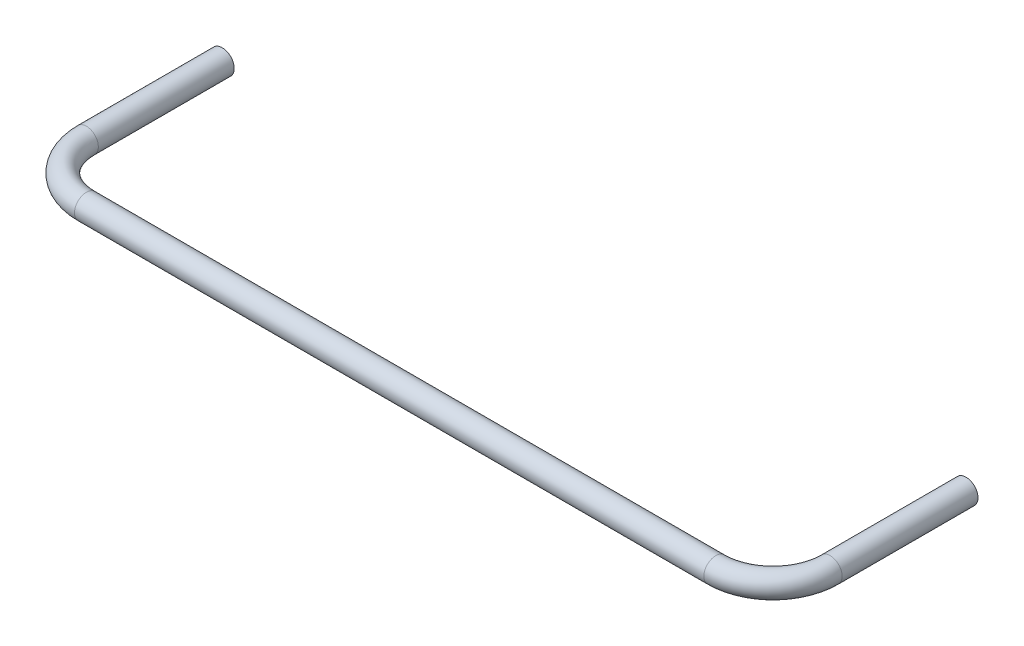
from build123d import *

# Parameters (mm, degrees)
SKETCH2_R = 8.35


with BuildPart() as part:
    # Sweep1: sweep along a path in Sketch1
    with BuildLine(Plane(origin=(0, 0, 0), x_dir=(1, 0, 0), z_dir=(0, 1, 0))) as sweep1_path:
        Line((-260.025, 0), (-260.025, -95))
        ThreePointArc((-260.025, -95), (-248.309271247, -123.284271247), (-220.025, -135))
        Line((-220.025, -135), (220.025, -135))
        ThreePointArc((220.025, -135), (248.309271247, -123.284271247), (260.025, -95))
        Line((260.025, -95), (260.025, 0))
    # Sketch2 → Sweep1 (sweep)
    with BuildSketch(Plane.XY):
        with Locations((260.025, 0)):
            Circle(SKETCH2_R)
    sweep(path=sweep1_path.line)


solid = part.part
